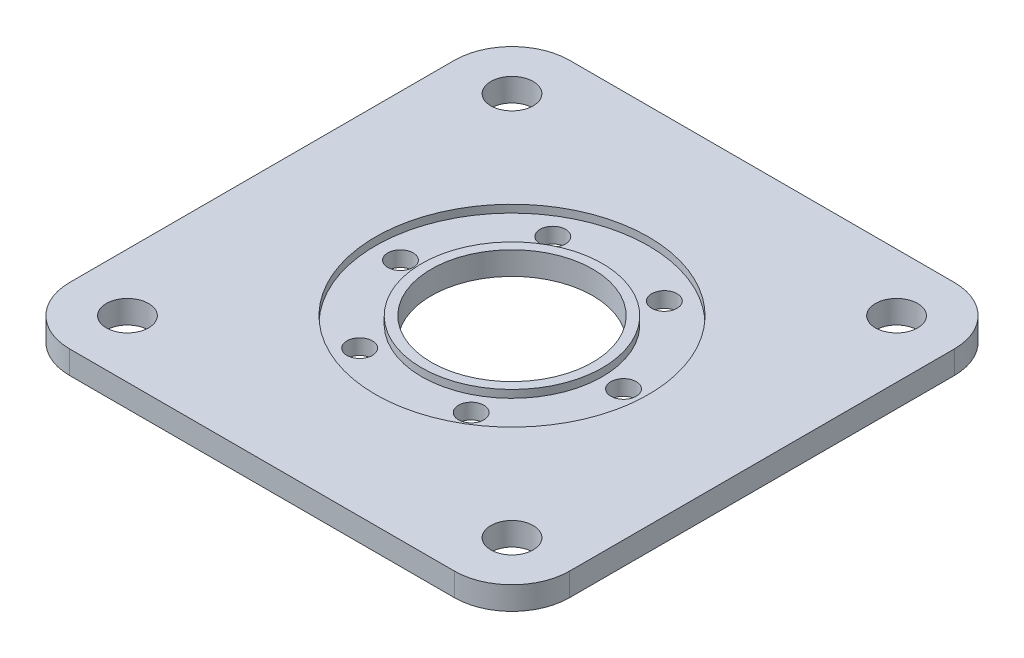
from build123d import *

# Parameters (mm, degrees)
SKETCH1_R                = 21
BOSS_EXTRUDE1_DEPTH      = 6
SKETCH2_R                = 35.5
SKETCH2_R_2              = 23.5
CUT_EXTRUDE1_DEPTH       = 2
SKETCH3_R                = 5.5
CUT_EXTRUDE2_DEPTH       = 1
CUT_EXTRUDE2_DEPTH_BACK  = 7
M6_CLEARANCE_HOLE1_D     = 6.6
M6_CLEARANCE_HOLE1_DEPTH = 4
CIRPATTERN1_COUNT        = 6


with BuildPart() as part:
    # Sketch1 → Boss-Extrude1 (new body)
    with BuildSketch(Plane(origin=(0, 0, 0), x_dir=(1, 0, 0), z_dir=(0, 1, 0))):
        with BuildLine():
            Line((-50, -65), (50, -65))
            ThreePointArc((50, -65), (60.606601718, -60.606601718), (65, -50))
            Line((65, -50), (65, 50))
            ThreePointArc((65, 50), (60.606601718, 60.606601718), (50, 65))
            Line((50, 65), (-50, 65))
            ThreePointArc((-50, 65), (-60.606601718, 60.606601718), (-65, 50))
            Line((-65, 50), (-65, -50))
            ThreePointArc((-65, -50), (-60.606601718, -60.606601718), (-50, -65))
        make_face()
        Circle(SKETCH1_R, mode=Mode.SUBTRACT)
    extrude(amount=BOSS_EXTRUDE1_DEPTH)

    # Sketch2 → Cut-Extrude1 (cut)
    with BuildSketch(Plane(origin=(0, 6, 0), x_dir=(1, 0, 0), z_dir=(0, 1, 0))):
        Circle(SKETCH2_R)
        Circle(SKETCH2_R_2, mode=Mode.SUBTRACT)
    extrude(amount=-CUT_EXTRUDE1_DEPTH, mode=Mode.SUBTRACT)

    # Sketch3 → Cut-Extrude2 (cut, two sides)
    with BuildSketch(Plane(origin=(0, 6, 0), x_dir=(1, 0, 0), z_dir=(0, 1, 0))) as cut_extrude2_sk:
        with Locations((-50, 50)):
            Circle(SKETCH3_R)
        with Locations((50, 50)):
            Circle(SKETCH3_R)
        with Locations((50, -50)):
            Circle(SKETCH3_R)
        with Locations((-50, -50)):
            Circle(SKETCH3_R)
    extrude(amount=CUT_EXTRUDE2_DEPTH, mode=Mode.SUBTRACT)
    extrude(cut_extrude2_sk.sketch, amount=-CUT_EXTRUDE2_DEPTH_BACK, mode=Mode.SUBTRACT)

    # M6 Clearance Hole1
    with Locations(Plane(origin=(-29, 4, 0), x_dir=(0, 0, 1), z_dir=(0, 1, 0))):
        with Locations((0, 0)):
            m6_clearance_hole1 = Hole(M6_CLEARANCE_HOLE1_D / 2, depth=M6_CLEARANCE_HOLE1_DEPTH)

    # CirPattern1: M6 Clearance Hole1 ×6 about axis
    cirpattern1_axis = Axis((0, 0, 0), (0, 1, 0))
    for i in range(1, CIRPATTERN1_COUNT):
        add(m6_clearance_hole1.rotate(cirpattern1_axis, i * 360 / CIRPATTERN1_COUNT), mode=Mode.SUBTRACT)


solid = part.part
